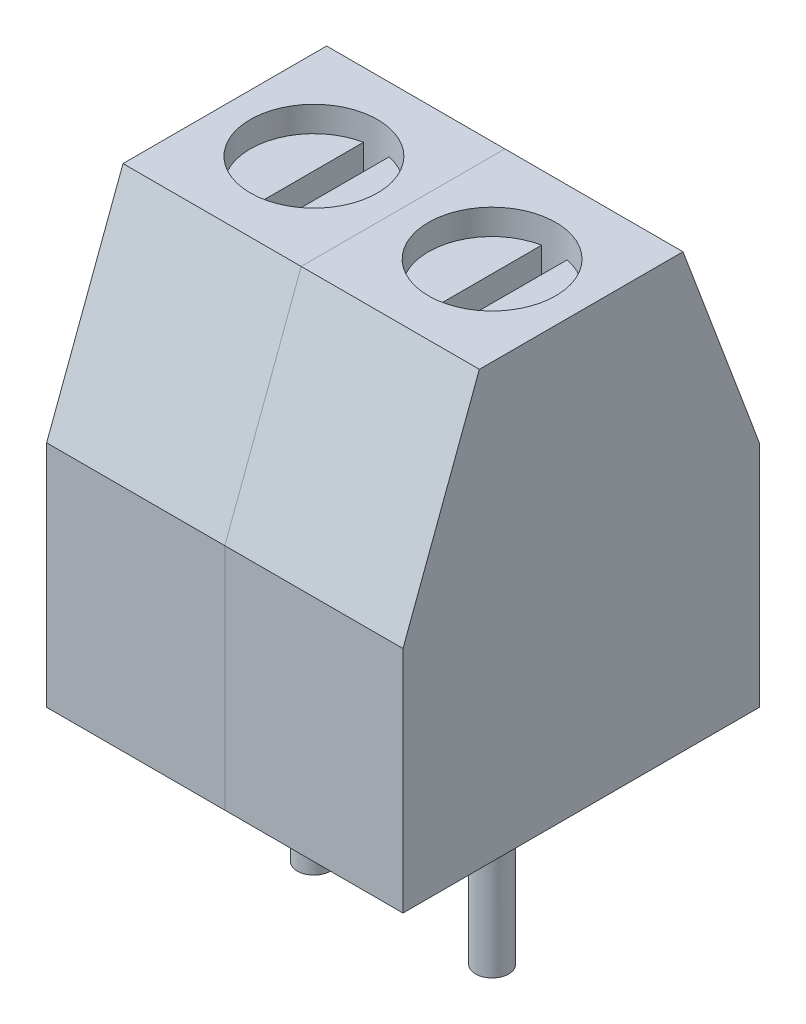
from build123d import *

# Parameters (mm, degrees)
EXTRUDE_1_DEPTH     = 3.5
SKETCH_3_W          = 3
SKETCH_3_H          = 4
CUT_EXTRUDE_1_DEPTH = 1.5
SKETCH_4_R          = 1.25
CUT_EXTRUDE_2_DEPTH = 0.5
CUT_EXTRUDE_3_DEPTH = 0.5
SKETCH_7_R          = 1
CUT_EXTRUDE_4_DEPTH = 3
SKETCH1_R           = 0.325
BOSS_EXTRUDE1_DEPTH = 3.5
LPATTERN1_COUNT     = 2
LPATTERN1_PITCH     = 3.5


with BuildPart() as part:
    # 스케치1 → 보스-돌출1 (new body)
    with BuildSketch(Plane(origin=(0, 0, 0), x_dir=(0, 0, -1), z_dir=(1, 0, 0))):
        Polygon((0, 0), (7, 0), (7, 4.5), (5.5, 8.5), (1.5, 8.5), (0, 4.5), align=None)
    extrude(amount=EXTRUDE_1_DEPTH)

    # 스케치3 → 컷-돌출1 (cut)
    with BuildSketch(Plane(origin=(0, 0, -7), x_dir=(-1, 0, 0), z_dir=(0, 0, -1))):
        with Locations((-1.75, 2.5)):
            Rectangle(SKETCH_3_W, SKETCH_3_H)
    extrude(amount=-CUT_EXTRUDE_1_DEPTH, mode=Mode.SUBTRACT)

    # 스케치4 → 컷-돌출2 (cut)
    with BuildSketch(Plane(origin=(0, 8.5, 0), x_dir=(1, 0, 0), z_dir=(0, 1, 0))):
        with Locations((1.75, 3.5)):
            Circle(SKETCH_4_R)
    extrude(amount=-CUT_EXTRUDE_2_DEPTH, mode=Mode.SUBTRACT)

    # 스케치5 → 컷-돌출3 (cut)
    with BuildSketch(Plane(origin=(0, 8, 0), x_dir=(1, 0, 0), z_dir=(0, 1, 0))):
        with BuildLine():
            Line((1.500050042, 4.724755085), (1.500050042, 2.275244915))
            ThreePointArc((1.500050042, 2.275244915), (1.75, 2.25), (1.999949958, 2.275244915))
            Line((1.999949958, 2.275244915), (1.999949958, 4.724755085))
            ThreePointArc((1.999949958, 4.724755085), (1.75, 4.75), (1.500050042, 4.724755085))
        make_face()
    extrude(amount=-CUT_EXTRUDE_3_DEPTH, mode=Mode.SUBTRACT)

    # 스케치7 → 컷-돌출4 (cut)
    with BuildSketch(Plane(origin=(0, 0, -5.5), x_dir=(-1, 0, 0), z_dir=(0, 0, -1))):
        with Locations((-1.75, 2)):
            Circle(SKETCH_7_R)
    extrude(amount=-CUT_EXTRUDE_4_DEPTH, mode=Mode.SUBTRACT)

    # Sketch1 → Boss-Extrude1 (add)
    with BuildSketch(Plane.XZ):
        with Locations((1.75, -3.5)):
            Circle(SKETCH1_R)
    extrude(amount=BOSS_EXTRUDE1_DEPTH)


with BuildPart() as lpattern1_1:
    # LPattern1: pattern copy
    add(part.part.moved(Location(Vector(1, 0, 0) * (1 * LPATTERN1_PITCH))))


solid = Compound([part.part, lpattern1_1.part])
